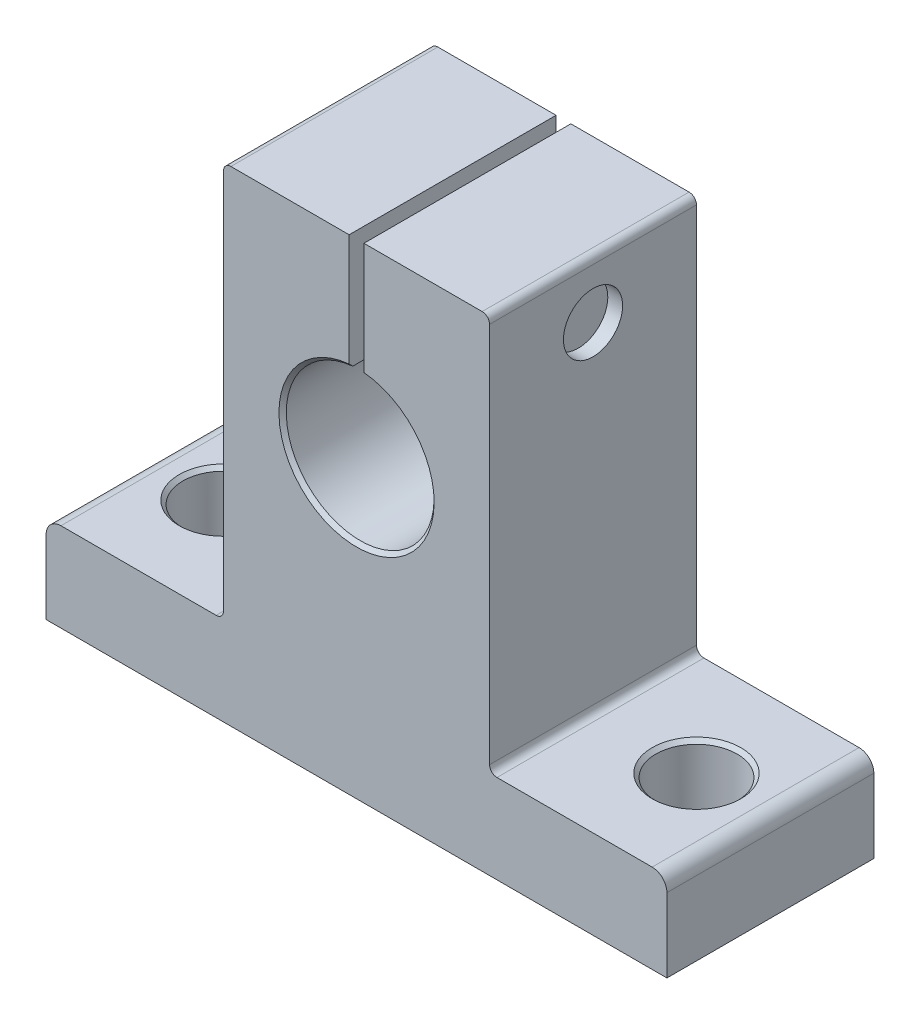
from build123d import *

# Parameters (mm, degrees)
BOSS_EXTRUDE1_DEPTH     = 14
SKETCH3_R               = 2.75
CUT_EXTRUDE1_DEPTH      = 1
CUT_EXTRUDE1_DEPTH_BACK = 6
FILLET1_R               = 1
FILLET2_R               = 0.5
CHAMFER1_SIZE           = 0.25
SKETCH4_R               = 3.1
CUT_EXTRUDE2_DEPTH      = 1
SKETCH5_R               = 3.1
SKETCH5_R_2             = 3
CUT_EXTRUDE3_DEPTH      = 4
CHAMFER2_SIZE           = 0.2
CUT_EXTRUDE4_DEPTH      = 2
SKETCH7_R               = 2
BOSS_EXTRUDE2_DEPTH     = 1
SKETCH8_R               = 2
CUT_EXTRUDE5_DEPTH      = 1
SKETCH9_R               = 1.732050808
CUT_EXTRUDE6_DEPTH      = 1
CUT_EXTRUDE6_TAPER      = 45


with BuildPart() as part:
    # Sketch1 → Boss-Extrude1 (new body)
    with BuildSketch(Plane.XY):
        with BuildLine():
            Line((-21, 0), (21, 0))
            Line((21, 0), (21, 6))
            Line((21, 6), (9, 6))
            Line((9, 6), (9, 32.8))
            Line((9, 32.8), (0.5, 32.8))
            Line((0.5, 32.8), (0.5, 24.974937186))
            ThreePointArc((0.5, 24.974937186), (0, 15), (-0.5, 24.974937186))
            Line((-0.5, 24.974937186), (-0.5, 32.8))
            Line((-0.5, 32.8), (-9, 32.8))
            Line((-9, 32.8), (-9, 6))
            Line((-9, 6), (-21, 6))
            Line((-21, 6), (-21, 0))
        make_face()
    extrude(amount=BOSS_EXTRUDE1_DEPTH)

    # Sketch3 → Cut-Extrude1 (cut, two sides)
    with BuildSketch(Plane.XZ) as cut_extrude1_sk:
        with Locations((-16, 7)):
            Circle(SKETCH3_R)
        with Locations((16, 7)):
            Circle(SKETCH3_R)
    extrude(amount=CUT_EXTRUDE1_DEPTH, mode=Mode.SUBTRACT)
    extrude(cut_extrude1_sk.sketch, amount=-CUT_EXTRUDE1_DEPTH_BACK, mode=Mode.SUBTRACT)

    # Fillet1
    fillet1_edges = [part.edges().sort_by_distance(p)[0] for p in [
        (-21, 6, 7),
        (21, 6, 7),
    ]]
    fillet(fillet1_edges, radius=FILLET1_R)

    # Fillet2
    fillet2_edges = [part.edges().sort_by_distance(p)[0] for p in [
        (-9, 6, 7),
        (-9, 32.8, 7),
        (9, 32.8, 7),
        (9, 6, 7),
    ]]
    fillet(fillet2_edges, radius=FILLET2_R)

    # Chamfer1
    chamfer1_edges = [part.edges().sort_by_distance(p)[0] for p in [
        (0, 15, 0),
        (0, 15, 14),
        (13.25, 6, 7),
        (13.25, 0, 7),
        (-18.75, 6, 7),
        (-18.75, 0, 7),
    ]]
    chamfer(chamfer1_edges, length=CHAMFER1_SIZE)

    # Sketch4 → Cut-Extrude2 (cut)
    with BuildSketch(Plane.ZY.offset(9)):
        with Locations((7, 28.9)):
            Circle(SKETCH4_R)
    extrude(amount=-CUT_EXTRUDE2_DEPTH, mode=Mode.SUBTRACT)

    # Sketch5 → Cut-Extrude3 (cut)
    with BuildSketch(Plane.ZY.offset(8)):
        with Locations((7, 28.9)):
            Circle(SKETCH5_R)
        with Locations((7, 28.9)):
            Circle(SKETCH5_R_2, mode=Mode.SUBTRACT)
    extrude(amount=-CUT_EXTRUDE3_DEPTH, mode=Mode.SUBTRACT)

    # Chamfer2
    chamfer2_edges = [part.edges().sort_by_distance(p)[0] for p in [
        (-8, 28.9, 4),
    ]]
    chamfer(chamfer2_edges, length=CHAMFER2_SIZE)

    # Sketch6 → Cut-Extrude4 (cut)
    with BuildSketch(Plane.ZY.offset(8)):
        Polygon((7.225455606, 30.617314697), (5.625489649, 29.953907631), (5.400034043, 28.236592934), (6.774544394, 27.182685303), (8.374510351, 27.846092369), (8.599965957, 29.563407066), align=None)
    extrude(amount=-CUT_EXTRUDE4_DEPTH, mode=Mode.SUBTRACT)

    # Sketch7 → Boss-Extrude2 (add)
    with BuildSketch(Plane(origin=(-0.5, 0, 0), x_dir=(0, 0, -1), z_dir=(1, 0, 0))):
        with Locations((-7, 28.9)):
            Circle(SKETCH7_R)
    extrude(amount=BOSS_EXTRUDE2_DEPTH)

    # Sketch8 → Cut-Extrude5 (cut)
    with BuildSketch(Plane(origin=(9, 0, 0), x_dir=(0, 0, -1), z_dir=(1, 0, 0))):
        with Locations((-7, 28.9)):
            Circle(SKETCH8_R)
    extrude(amount=-CUT_EXTRUDE5_DEPTH, mode=Mode.SUBTRACT)

    # Sketch9 → Cut-Extrude6 (cut)
    with BuildSketch(Plane.ZY.offset(8)):
        with Locations((7, 28.9)):
            Circle(SKETCH9_R)
    extrude(amount=-CUT_EXTRUDE6_DEPTH, taper=CUT_EXTRUDE6_TAPER, mode=Mode.SUBTRACT)


solid = part.part
